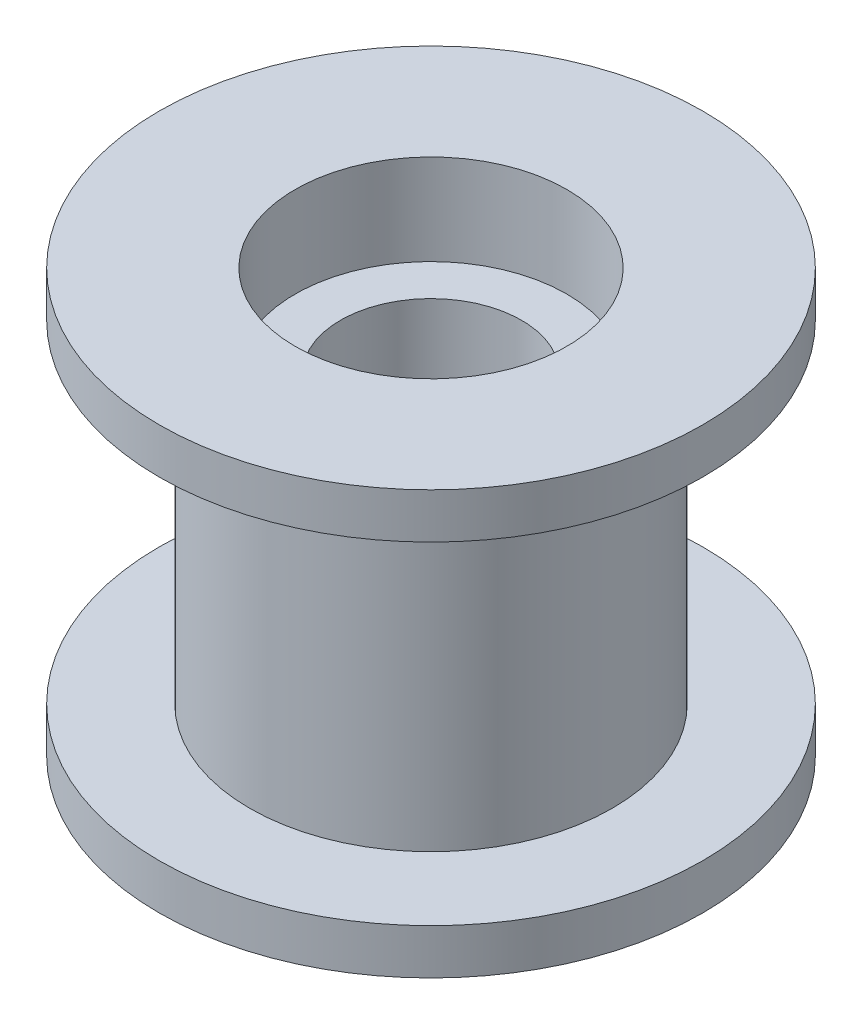
from build123d import *

# Parameters (mm, degrees)
SKETCH1_R           = 6
SKETCH1_R_2         = 4.5
BOSS_EXTRUDE1_DEPTH = 5.5
SKETCH2_R           = 9
SKETCH2_R_2         = 4.5
BOSS_EXTRUDE2_DEPTH = 1.5
SKETCH3_R           = 4.5
SKETCH3_R_2         = 3
BOSS_EXTRUDE3_DEPTH = 4


with BuildPart() as part:
    # Sketch1 → Boss-Extrude1 (new body, symmetric)
    with BuildSketch(Plane(origin=(0, 0, 0), x_dir=(1, 0, 0), z_dir=(0, 1, 0))):
        Circle(SKETCH1_R)
        Circle(SKETCH1_R_2, mode=Mode.SUBTRACT)
    extrude(amount=BOSS_EXTRUDE1_DEPTH, both=True)

    # Sketch2 → Boss-Extrude2 (add)
    with BuildSketch(Plane(origin=(0, 5.5, 0), x_dir=(1, 0, 0), z_dir=(0, 1, 0))):
        Circle(SKETCH2_R)
        Circle(SKETCH2_R_2, mode=Mode.SUBTRACT)
    boss_extrude2 = extrude(amount=BOSS_EXTRUDE2_DEPTH)

    # Mirror1: Boss-Extrude2 across plane
    add(boss_extrude2.mirror(Plane.ZX))

    # Sketch3 → Boss-Extrude3 (add, symmetric)
    with BuildSketch(Plane(origin=(0, 0, 0), x_dir=(1, 0, 0), z_dir=(0, 1, 0))):
        Circle(SKETCH3_R)
        Circle(SKETCH3_R_2, mode=Mode.SUBTRACT)
    extrude(amount=BOSS_EXTRUDE3_DEPTH, both=True)


solid = part.part
